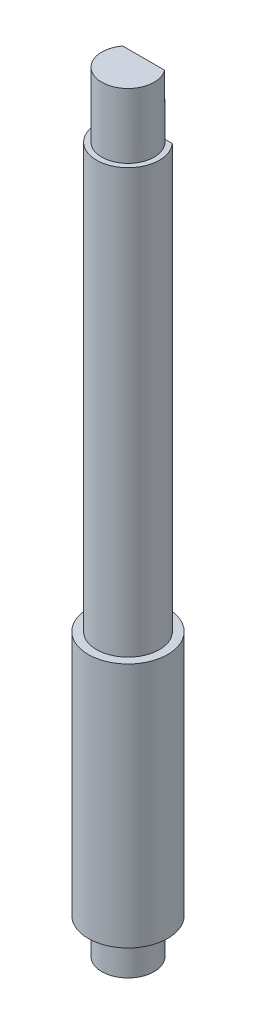
from build123d import *

# Parameters (mm, degrees)
CUT_EXTRUDE_2_DEPTH = 23.35
CUT_EXTRUDE_3_DEPTH = 1.4


with BuildPart() as part:
    # 草图1 → 旋转2 (revolve)
    with BuildSketch(Plane.XY):
        Polygon((1.25, 5.954469818), (0, 5.954469818), (0, -30.845530182), (1.25, -30.845530182), (1.25, -29.145530182), (1.9, -29.145530182), (1.9, -17.395530182), (1.5, -17.395530182), (1.5, 2.854469818), (1.25, 2.854469818), align=None)
    revolve(axis=Axis((0, 5.954469818, 0), (0, -1, 0)))

    # 草图4 → 切除-拉伸2 (cut)
    with BuildSketch(Plane(origin=(0, 5.954469818, 0), x_dir=(1, 0, 0), z_dir=(0, 1, 0))):
        with BuildLine():
            Line((-1.118033989, 1), (1.118033989, 1))
            ThreePointArc((1.118033989, 1), (0, 1.5), (-1.118033989, 1))
        make_face()
    extrude(amount=-CUT_EXTRUDE_2_DEPTH, mode=Mode.SUBTRACT)

    # 草图5 → 切除-拉伸3 (cut)
    with BuildSketch(Plane(origin=(0, 5.954469818, 0), x_dir=(1, 0, 0), z_dir=(0, 1, 0))):
        with BuildLine():
            Line((-1, 0.75), (1, 0.75))
            ThreePointArc((1, 0.75), (0, 1.25), (-1, 0.75))
        make_face()
    extrude(amount=-CUT_EXTRUDE_3_DEPTH, mode=Mode.SUBTRACT)


solid = part.part
